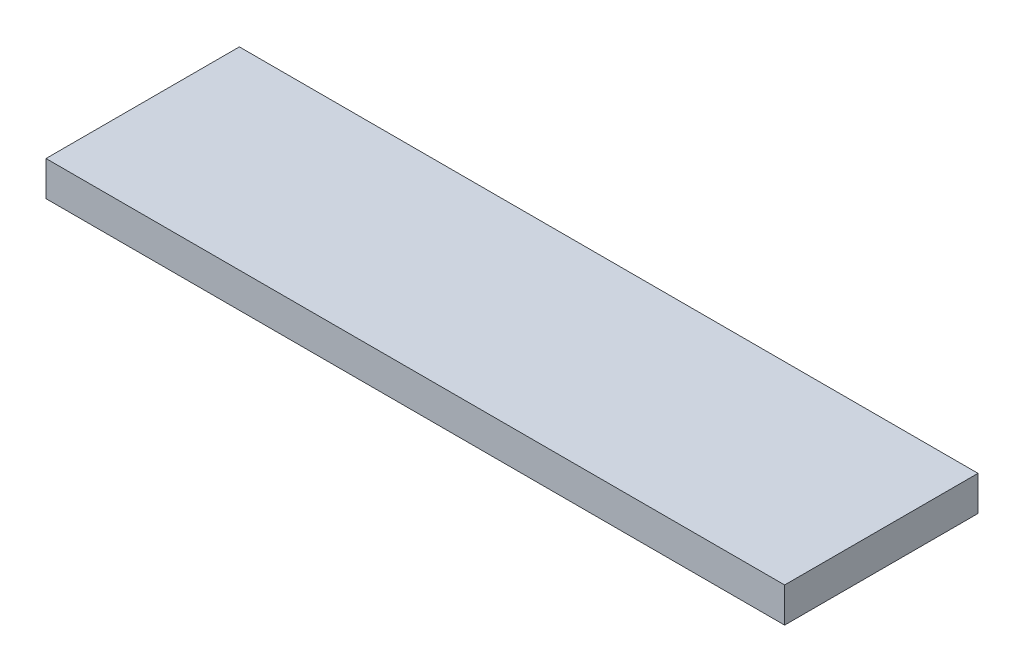
from build123d import *

# Parameters (mm, degrees)
SKETCH1_W           = 382
SKETCH1_H           = 100
BOSS_EXTRUDE1_DEPTH = 18


with BuildPart() as part:
    # Sketch1 → Boss-Extrude1 (new body)
    with BuildSketch(Plane(origin=(0, 0, 0), x_dir=(1, 0, 0), z_dir=(0, 1, 0))):
        with Locations((191, 50)):
            Rectangle(SKETCH1_W, SKETCH1_H)
    extrude(amount=BOSS_EXTRUDE1_DEPTH)


solid = part.part
